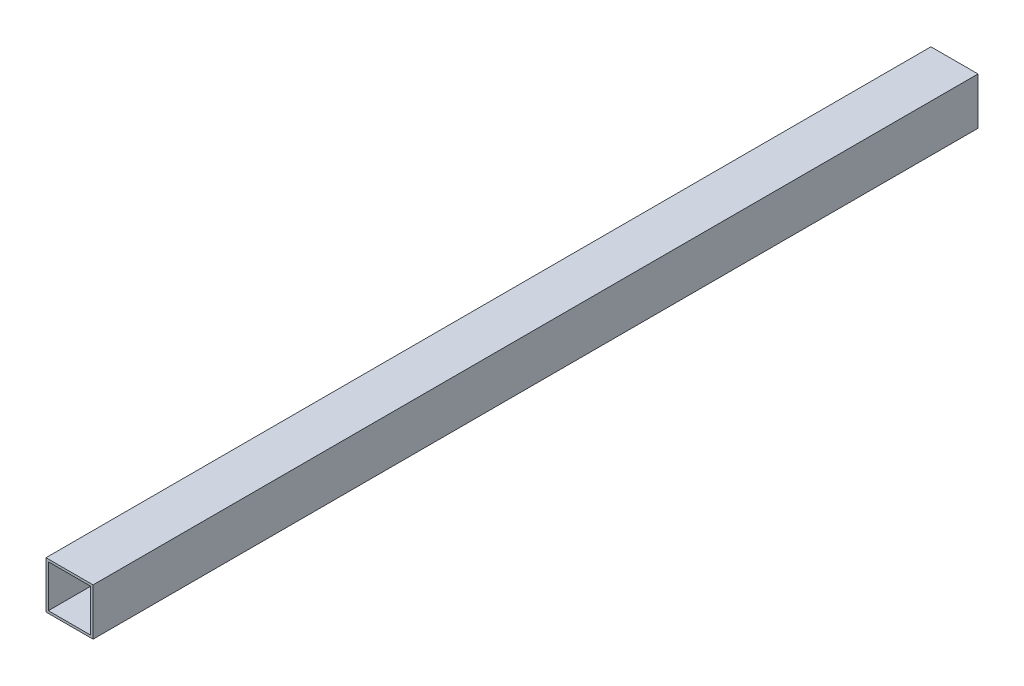
from build123d import *

# Parameters (mm, degrees)
SKETCH1_W           = 100
SKETCH1_H           = 100
SKETCH1_W_2         = 90
SKETCH1_H_2         = 90
BOSS_EXTRUDE1_DEPTH = 940


with BuildPart() as part:
    # Sketch1 → Boss-Extrude1 (new body, symmetric)
    with BuildSketch(Plane.XY):
        Rectangle(SKETCH1_W, SKETCH1_H)
        Rectangle(SKETCH1_W_2, SKETCH1_H_2, mode=Mode.SUBTRACT)
    extrude(amount=BOSS_EXTRUDE1_DEPTH, both=True)


solid = part.part
